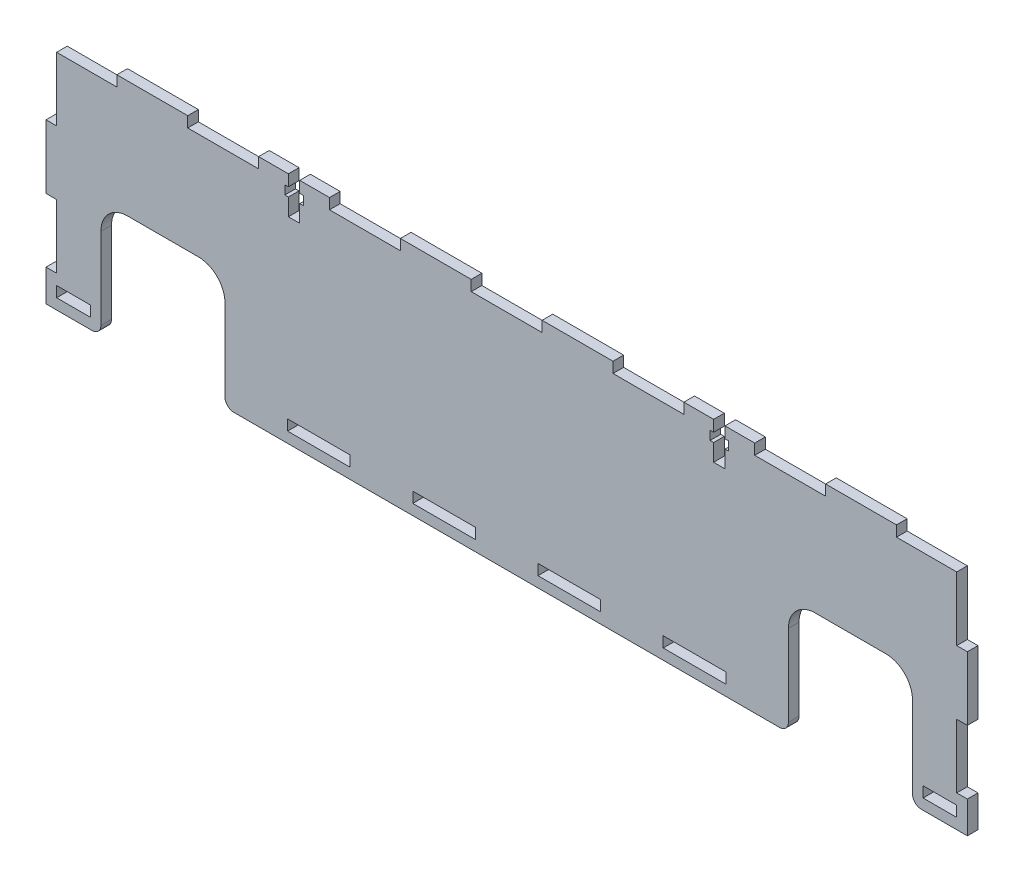
from build123d import *

# Parameters (mm, degrees)
BOSS_EXTRUDE1_DEPTH     = 3
SKETCH2_W               = 3
SKETCH2_H               = 18
SKETCH2_W_2             = 17.666666666
SKETCH2_H_2             = 3
SKETCH2_W_3             = 17.666666667
SKETCH2_W_4             = 9.5
SKETCH2_W_5             = 20
CUT_EXTRUDE1_DEPTH      = 1
CUT_EXTRUDE1_DEPTH_BACK = 4
SKETCH3_W               = 3.2
SKETCH3_H               = 10.5
SKETCH3_W_2             = 5.2
SKETCH3_H_2             = 2.5
CUT_EXTRUDE2_DEPTH      = 1
CUT_EXTRUDE2_DEPTH_BACK = 4
FILLET1_R               = 7.5
FILLET2_R               = 2.5


with BuildPart() as part:
    # Sketch1 → Boss-Extrude1 (new body)
    with BuildSketch(Plane.XY):
        Polygon((-130, 33), (130, 33), (130, -33), (114.5, -33), (114.5, 0), (79.5, 0), (79.5, -33), (-79.5, -33), (-79.5, 0), (-114.5, 0), (-114.5, -33), (-130, -33), align=None)
    extrude(amount=BOSS_EXTRUDE1_DEPTH)

    # Sketch2 → Cut-Extrude1 (cut, two sides)
    with BuildSketch(Plane.XY.offset(3)) as cut_extrude1_sk:
        with Locations((-128.5, 21)):
            Rectangle(SKETCH2_W, SKETCH2_H)
        with Locations((-128.5, -15)):
            Rectangle(SKETCH2_W, SKETCH2_H)
        with Locations((-53, -28.5)):
            Rectangle(SKETCH2_W_2, SKETCH2_H_2)
        with Locations((-17.666666666, -28.5)):
            Rectangle(SKETCH2_W_3, SKETCH2_H_2)
        with Locations((17.666666666, -28.5)):
            Rectangle(SKETCH2_W_3, SKETCH2_H_2)
        with Locations((53, -28.5)):
            Rectangle(SKETCH2_W_2, SKETCH2_H_2)
        with Locations((122.25, -28.5)):
            Rectangle(SKETCH2_W_4, SKETCH2_H_2)
        with Locations((128.5, -15)):
            Rectangle(SKETCH2_W, SKETCH2_H)
        with Locations((128.5, 21)):
            Rectangle(SKETCH2_W, SKETCH2_H)
        Polygon((130, 33), (110, 33), (110, 30), (127, 30), (130, 30), align=None)
        with Locations((80, 31.5)):
            Rectangle(SKETCH2_W_5, SKETCH2_H_2)
        with Locations((40, 31.5)):
            Rectangle(SKETCH2_W_5, SKETCH2_H_2)
        with Locations((-40, 31.5)):
            Rectangle(SKETCH2_W_5, SKETCH2_H_2)
        with Locations((-80, 31.5)):
            Rectangle(SKETCH2_W_5, SKETCH2_H_2)
        with Locations((0, 31.5)):
            Rectangle(SKETCH2_W_5, SKETCH2_H_2)
        with Locations((-120, 31.5)):
            Rectangle(SKETCH2_W_5, SKETCH2_H_2)
        with Locations((-122.25, -28.5)):
            Rectangle(SKETCH2_W_4, SKETCH2_H_2)
    extrude(amount=CUT_EXTRUDE1_DEPTH, mode=Mode.SUBTRACT)
    extrude(cut_extrude1_sk.sketch, amount=-CUT_EXTRUDE1_DEPTH_BACK, mode=Mode.SUBTRACT)

    # Sketch3 → Cut-Extrude2 (cut, two sides)
    with BuildSketch(Plane.XY.offset(3)) as cut_extrude2_sk:
        with Locations((-60, 27.75)):
            Rectangle(SKETCH3_W, SKETCH3_H)
        with Locations((60, 27.75)):
            Rectangle(SKETCH3_W, SKETCH3_H)
        with Locations((-60, 28.575)):
            Rectangle(SKETCH3_W_2, SKETCH3_H_2)
        with Locations((60, 28.575)):
            Rectangle(SKETCH3_W_2, SKETCH3_H_2)
    extrude(amount=CUT_EXTRUDE2_DEPTH, mode=Mode.SUBTRACT)
    extrude(cut_extrude2_sk.sketch, amount=-CUT_EXTRUDE2_DEPTH_BACK, mode=Mode.SUBTRACT)

    # Fillet1
    fillet1_edges = [part.edges().sort_by_distance(p)[0] for p in [
        (114.5, 0, 1.5),
        (79.5, 0, 1.5),
        (-79.5, 0, 1.5),
        (-114.5, 0, 1.5),
    ]]
    fillet(fillet1_edges, radius=FILLET1_R)

    # Fillet2
    fillet2_edges = [part.edges().sort_by_distance(p)[0] for p in [
        (114.5, -33, 1.5),
        (79.5, -33, 1.5),
        (-79.5, -33, 1.5),
        (-114.5, -33, 1.5),
    ]]
    fillet(fillet2_edges, radius=FILLET2_R)


solid = part.part
